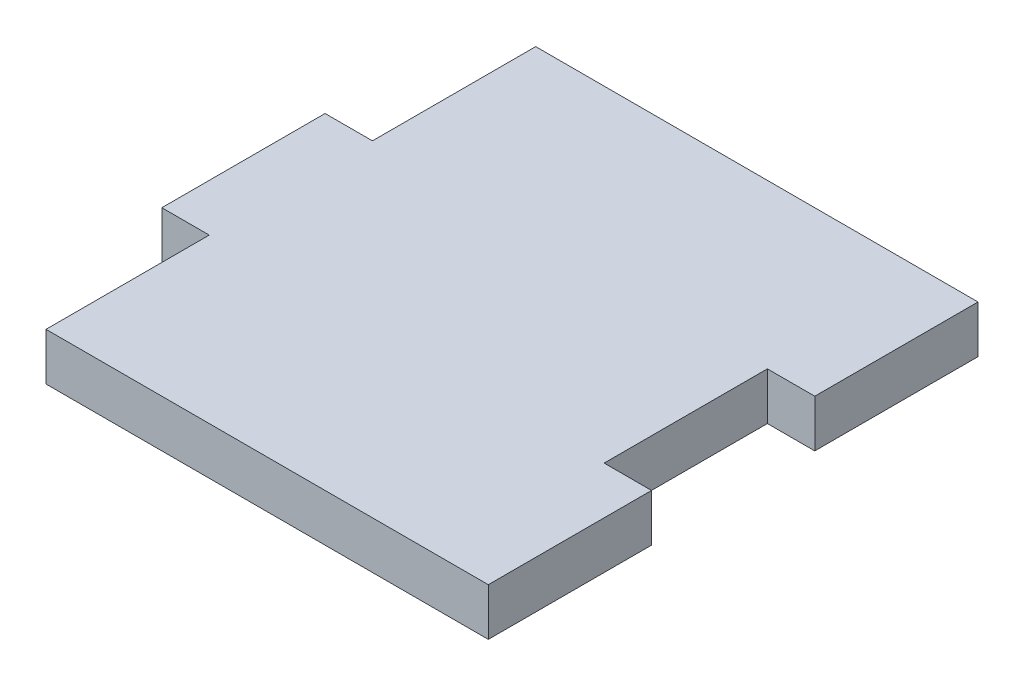
from build123d import *

# Parameters (mm, degrees)
BOSS_EXTRUDE1_DEPTH = 4.5
SKETCH2_W           = 51.255573275
SKETCH2_H           = 30.547230998
CUT_EXTRUDE1_DEPTH  = 5.5


with BuildPart() as part:
    # Sketch1 → Boss-Extrude1 (new body)
    with BuildSketch(Plane(origin=(0, 0, 0), x_dir=(1, 0, 0), z_dir=(0, 1, 0))):
        Polygon((-21, 0), (-21, -15.5), (-25.5, -15.5), (-25.5, -31), (-21, -31), (-21, -35.5), (-16.5, -35.5), (-16.5, -31), (0, -31), (0, -35.5), (4.5, -35.5), (4.5, -31), (16.5, -31), (16.5, -15.5), (21, -15.5), (21, 0), (16.5, 0), (16.5, 15.5), (21, 15.5), (21, 31), (-21, 31), (-21, 15.5), (-25.5, 15.5), (-25.5, 0), align=None)
    extrude(amount=BOSS_EXTRUDE1_DEPTH)

    # Sketch2 → Cut-Extrude1 (cut, through all)
    with BuildSketch(Plane(origin=(0, 4.5, 0), x_dir=(1, 0, 0), z_dir=(0, 1, 0))):
        with Locations((0.127786638, -30.773615499)):
            Rectangle(SKETCH2_W, SKETCH2_H)
    extrude(amount=-CUT_EXTRUDE1_DEPTH, mode=Mode.SUBTRACT)


solid = part.part
